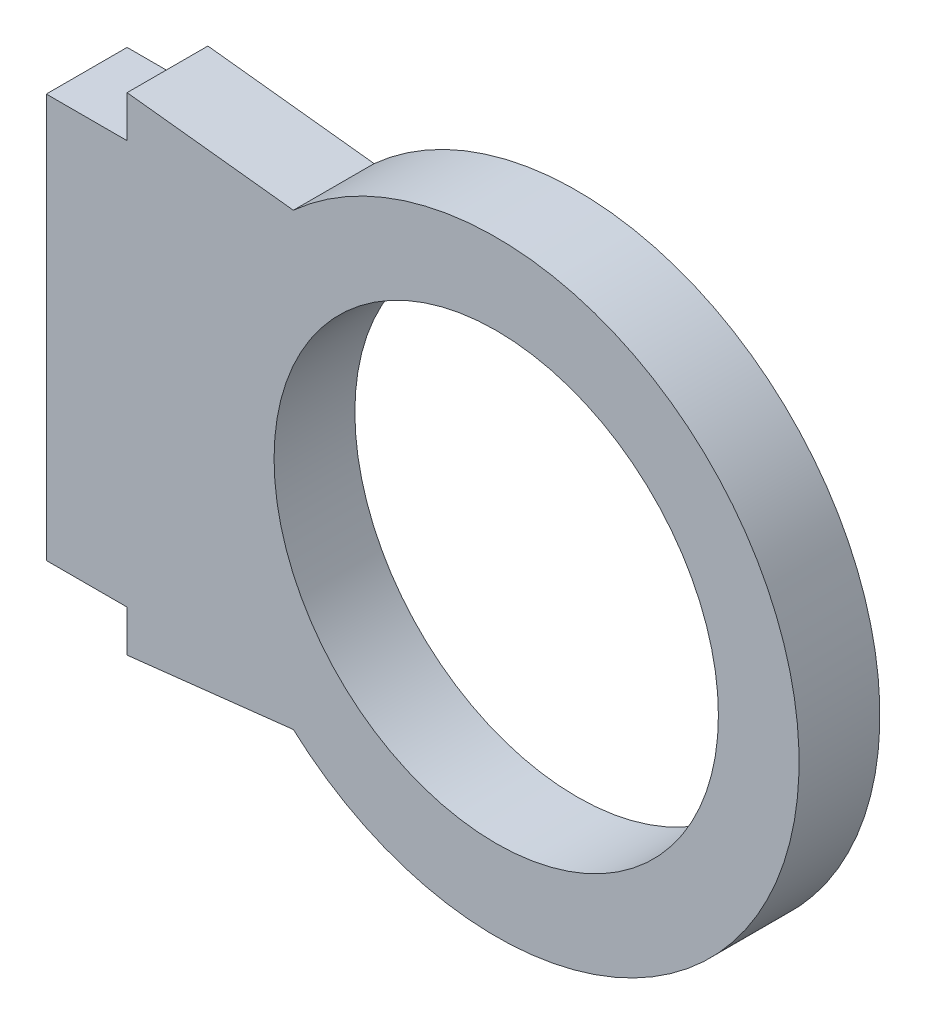
from build123d import *
from build123d.topology import SkipClean

# Parameters (mm, degrees)
CROQUIS1_R              = 4.2
SALIENTE_EXTRUIR1_DEPTH = 4
SALIENTE_EXTRUIR2_DEPTH = 4
CROQUIS2_3_R            = 4.2
CORTAR_EXTRUIR1_DEPTH   = 4


with BuildPart() as part:
    # Croquis1 → Saliente-Extruir1 (new body)
    with BuildSketch(Plane.XY):
        with BuildLine():
            Line((2, 14.378089444), (-2, 14.378089444))
            Line((-2, 14.378089444), (-2, -5.621910556))
            Line((-2, -5.621910556), (2, -5.621910556))
            Line((2, -5.621910556), (2, -7.681185842))
            Line((2, -7.681185842), (20.292265124, -5.621910556))
            ThreePointArc((20.292265124, -5.621910556), (30.276145575, 4.378089444), (20.292265124, 14.378089444))
            Line((20.292265124, 14.378089444), (2, 16.43736473))
            Line((2, 16.43736473), (2, 14.378089444))
        make_face()
        with Locations((20.276132562, 4.378089444)):
            Circle(CROQUIS1_R, mode=Mode.SUBTRACT)
    extrude(amount=SALIENTE_EXTRUIR1_DEPTH)

    # Croquis2 → Saliente-Extruir2 (add)
    with BuildSketch(Plane.XY.offset(4)):
        with BuildLine():
            ThreePointArc((10.23085334, -6.754586935), (35.270935596, 4.378089444), (10.23085334, 15.510765823))
            Line((10.23085334, 15.510765823), (16.704250968, 14.782014755))
            ThreePointArc((16.704250968, 14.782014755), (26.667896891, 13.33048291), (31.276132562, 4.378089444))
            ThreePointArc((31.276132562, 4.378089444), (26.667896891, -4.574304022), (16.704250968, -6.025835867))
            Line((16.704250968, -6.025835867), (10.23085334, -6.754586935))
        make_face()
    extrude(amount=-SALIENTE_EXTRUIR2_DEPTH)

    # Croquis2_3 → Cortar-Extruir1 (cut)
    with SkipClean():  # the faces are left unmerged after this step: merging them gives an invalid solid
        with BuildSketch(Plane.XY.offset(4)):
            with BuildLine():
                ThreePointArc((16.704250968, 14.782014755), (15.618415295, 14.343312465), (14.585373454, 13.791657353))
                ThreePointArc((14.585373454, 13.791657353), (9.276534219, 4.472091013), (14.425321372, -4.936845253))
                ThreePointArc((14.425321372, -4.936845253), (15.533426587, -5.546966729), (16.704250968, -6.025835867))
                Line((16.704250968, -6.025835867), (20.292265124, -5.621910556))
                ThreePointArc((20.292265124, -5.621910556), (30.276145575, 4.378089444), (20.292265124, 14.378089444))
                Line((20.292265124, 14.378089444), (16.704250968, 14.782014755))
            make_face()
            with Locations((20.276132562, 4.378089444)):
                Circle(CROQUIS2_3_R, mode=Mode.SUBTRACT)
        extrude(amount=-CORTAR_EXTRUIR1_DEPTH, mode=Mode.SUBTRACT)


solid = part.part
